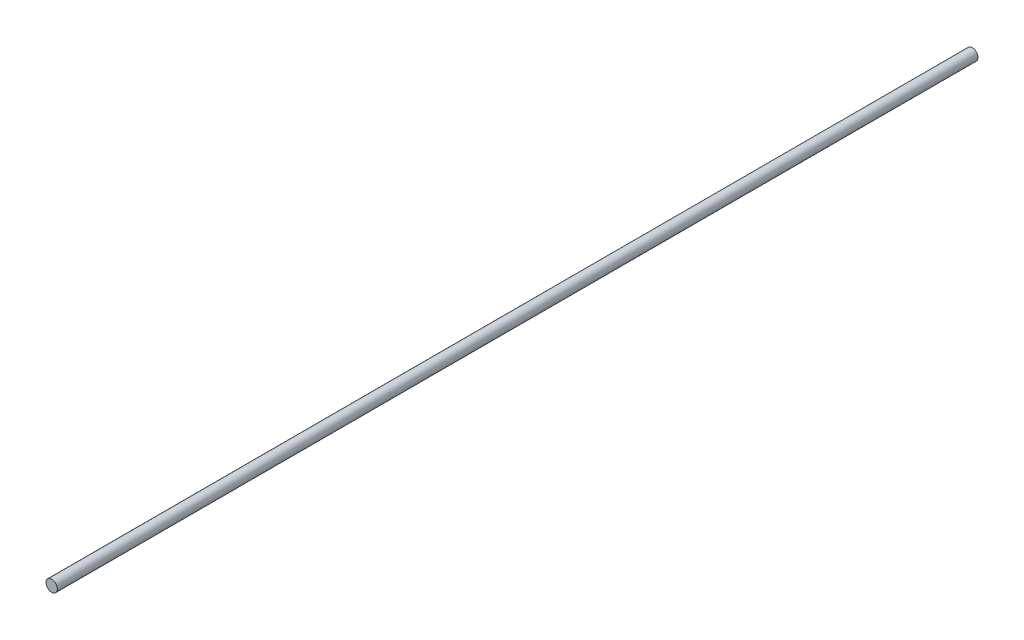
from build123d import *

# Parameters (mm, degrees)
ESQUISSE1_R        = 4
BOSS_EXTRU_1_DEPTH = 648


with BuildPart() as part:
    # Esquisse1 → Boss.-Extru.1 (new body)
    with BuildSketch(Plane.XY):
        Circle(ESQUISSE1_R)
    extrude(amount=BOSS_EXTRU_1_DEPTH)


solid = part.part
